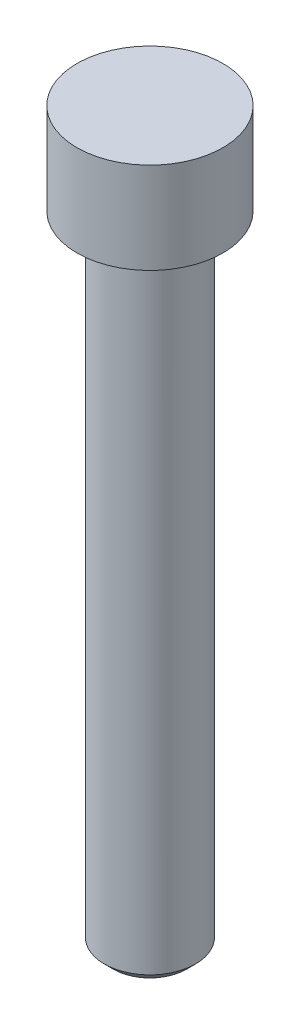
from build123d import *

# Parameters (mm, degrees)
SKETCH1_R           = 8
BOSS_EXTRUDE1_DEPTH = 10
SKETCH2_R           = 5
BOSS_EXTRUDE2_DEPTH = 70
CHAMFER1_SIZE       = 1


with BuildPart() as part:
    # Sketch1 → Boss-Extrude1 (new body)
    with BuildSketch(Plane(origin=(0, 0, 0), x_dir=(1, 0, 0), z_dir=(0, 1, 0))):
        Circle(SKETCH1_R)
    extrude(amount=BOSS_EXTRUDE1_DEPTH)

    # Sketch2 → Boss-Extrude2 (add)
    with BuildSketch(Plane.XZ):
        Circle(SKETCH2_R)
    extrude(amount=BOSS_EXTRUDE2_DEPTH)

    # Chamfer1
    chamfer1_edges = [part.edges().sort_by_distance(p)[0] for p in [
        (-5, -70, 0),
    ]]
    chamfer(chamfer1_edges, length=CHAMFER1_SIZE)


solid = part.part
